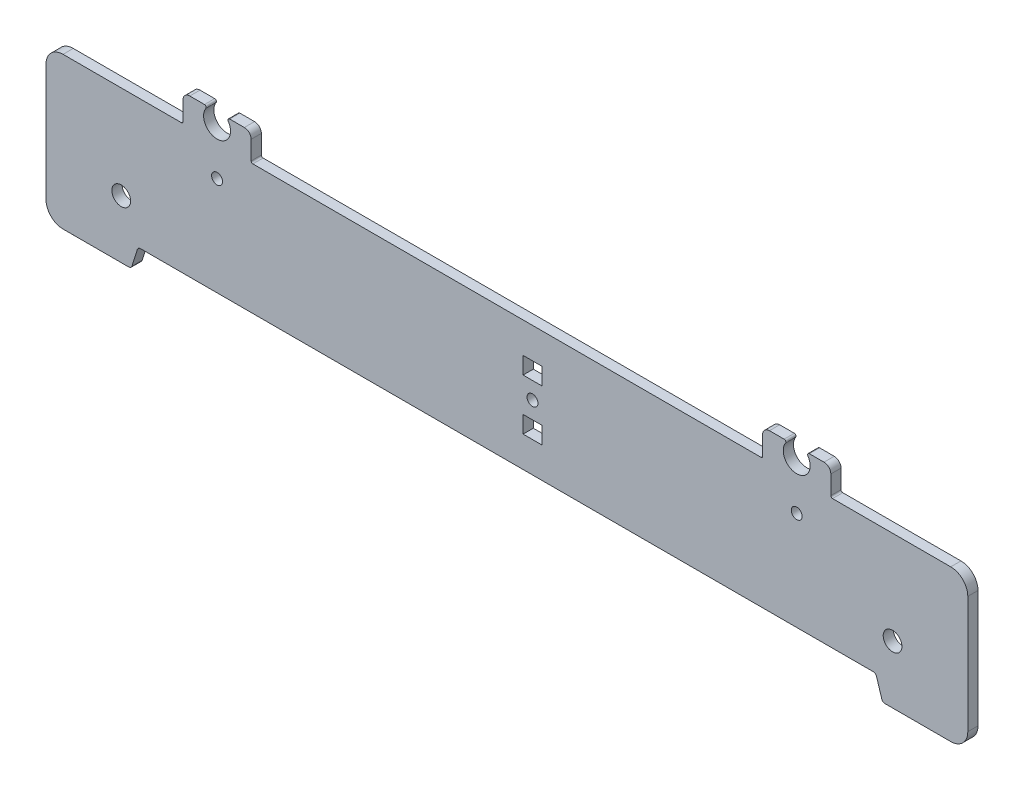
from build123d import *

# Parameters (mm, degrees)
MODEL_R                 = 1.60291439
MODEL_R_2               = 2.755009107
MODEL_W                 = 5.5
MODEL_H                 = 5
MODEL_H_2               = 5.009107468
SALIENTE_EXTRUIR1_DEPTH = 3


with BuildPart() as part:
    # Model → Saliente-Extruir1 (new body)
    with BuildSketch(Plane.XY):
        with BuildLine():
            Line((146.331612735, 52.084906554), (71.693408409, 52.084905051))
            ThreePointArc((71.693408409, 52.084905051), (71.339211023, 52.231618412), (71.192497662, 52.585815798))
            Line((71.192497662, 52.585815798), (71.192497662, 58.093853412))
            ThreePointArc((71.192497662, 58.093853412), (70.605644218, 59.510642955), (69.188854675, 60.097496399))
            Line((69.188854675, 60.097496399), (64.864840233, 60.097496399))
            ThreePointArc((64.864840233, 60.097496399), (64.422309224, 59.831272426), (64.45017085, 59.315585867))
            ThreePointArc((64.45017085, 59.315585867), (61.174282726, 53.138492666), (57.898394601, 59.315585867))
            ThreePointArc((57.898394601, 59.315585867), (57.926256228, 59.831272427), (57.483725218, 60.097496399))
            Line((57.483725218, 60.097496399), (53.159710777, 60.097496399))
            ThreePointArc((53.159710777, 60.097496399), (51.742921234, 59.510642955), (51.15606779, 58.093853412))
            Line((51.15606779, 58.093853412), (51.15606779, 52.585818804))
            ThreePointArc((51.15606779, 52.585818804), (51.009354429, 52.231621418), (50.655157043, 52.084908057))
            Line((50.655157043, 52.084908057), (20.928604766, 52.084908057))
            Line((20.928604766, 52.084908057), (15.919497298, 52.084908057))
            ThreePointArc((15.919497298, 52.084908057), (12.37752344, 50.617774447), (10.91038983, 47.075800589))
            Line((10.91038983, 47.075800589), (10.91038983, 12.625568804))
            ThreePointArc((10.91038983, 12.625568804), (12.377524274, 9.083594111), (15.919499658, 7.616461335))
            Line((15.919499658, 7.616461335), (35.219821515, 7.616461335))
            ThreePointArc((35.219821515, 7.616461335), (35.81301385, 7.810960614), (36.17587477, 8.318936073))
            Line((36.17587477, 8.318936073), (37.739622557, 13.313231589))
            ThreePointArc((37.739622557, 13.313231589), (38.102483477, 13.821207048), (38.695675812, 14.015706326))
            Line((38.695675812, 14.015706326), (146.331612735, 14.013271547))
            Line((146.331612735, 14.013271547), (253.967549659, 14.015706326))
            ThreePointArc((253.967549659, 14.015706326), (254.560741993, 13.821207048), (254.923602913, 13.313231589))
            Line((254.923602913, 13.313231589), (256.487350701, 8.318936073))
            ThreePointArc((256.487350701, 8.318936073), (256.85021162, 7.810960614), (257.443403955, 7.616461335))
            Line((257.443403955, 7.616461335), (276.743725812, 7.616461335))
            ThreePointArc((276.743725812, 7.616461335), (280.285701196, 9.083594111), (281.75283564, 12.625568804))
            Line((281.75283564, 12.625568804), (281.75283564, 47.075800589))
            ThreePointArc((281.75283564, 47.075800589), (280.285702031, 50.617774447), (276.743728172, 52.084908057))
            Line((276.743728172, 52.084908057), (271.734620704, 52.084908057))
            Line((271.734620704, 52.084908057), (242.008068427, 52.084908057))
            ThreePointArc((242.008068427, 52.084908057), (241.653871041, 52.231621418), (241.50715768, 52.585818804))
            Line((241.50715768, 52.585818804), (241.50715768, 58.093853412))
            ThreePointArc((241.50715768, 58.093853412), (240.920304237, 59.510642955), (239.503514693, 60.097496399))
            Line((239.503514693, 60.097496399), (235.179500252, 60.097496399))
            ThreePointArc((235.179500252, 60.097496399), (234.736969242, 59.831272427), (234.764830869, 59.315585867))
            ThreePointArc((234.764830869, 59.315585867), (231.488942744, 53.138492666), (228.21305462, 59.315585867))
            ThreePointArc((228.21305462, 59.315585867), (228.240916247, 59.831272426), (227.798385238, 60.097496399))
            Line((227.798385238, 60.097496399), (223.474370795, 60.097496399))
            ThreePointArc((223.474370795, 60.097496399), (222.057581252, 59.510642955), (221.470727808, 58.093853412))
            Line((221.470727808, 58.093853412), (221.470727808, 52.585815798))
            ThreePointArc((221.470727808, 52.585815798), (221.324014447, 52.231618412), (220.969817061, 52.084905051))
            Line((220.969817061, 52.084905051), (146.331612735, 52.084906554))
        make_face()
        with Locations((61.174282726, 43.070186654)):
            Circle(MODEL_R, mode=Mode.SUBTRACT)
        with Locations((231.488942744, 43.070186654)):
            Circle(MODEL_R, mode=Mode.SUBTRACT)
        with Locations((153.845273937, 33.04908905)):
            Circle(MODEL_R, mode=Mode.SUBTRACT)
        with Locations((33.011476123, 24.647426727)):
            Circle(MODEL_R_2, mode=Mode.SUBTRACT)
        with Locations((259.651749347, 24.647426727)):
            Circle(MODEL_R_2, mode=Mode.SUBTRACT)
        with Locations((153.84026483, 40.558196518)):
            Rectangle(MODEL_W, MODEL_H, mode=Mode.SUBTRACT)
        with Locations((153.84026483, 25.535427848)):
            Rectangle(MODEL_W, MODEL_H_2, mode=Mode.SUBTRACT)
    extrude(amount=SALIENTE_EXTRUIR1_DEPTH)


solid = part.part
